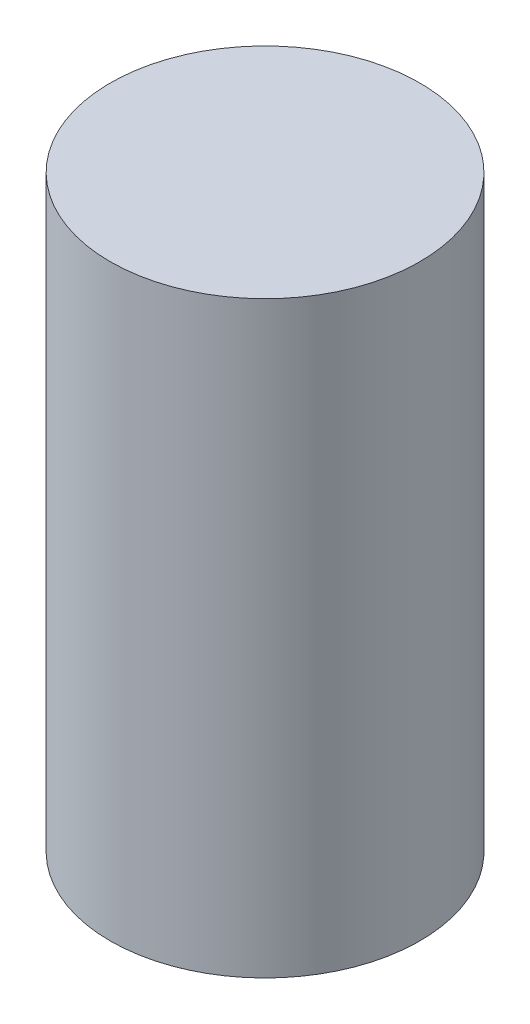
from build123d import *

# Parameters (mm, degrees)
SKETCH1_R           = 5
BOSS_EXTRUDE1_DEPTH = 19


with BuildPart() as part:
    # Sketch1 → Boss-Extrude1 (new body)
    with BuildSketch(Plane(origin=(0, 0, 0), x_dir=(1, 0, 0), z_dir=(0, 1, 0))):
        Circle(SKETCH1_R)
    extrude(amount=BOSS_EXTRUDE1_DEPTH)


solid = part.part
